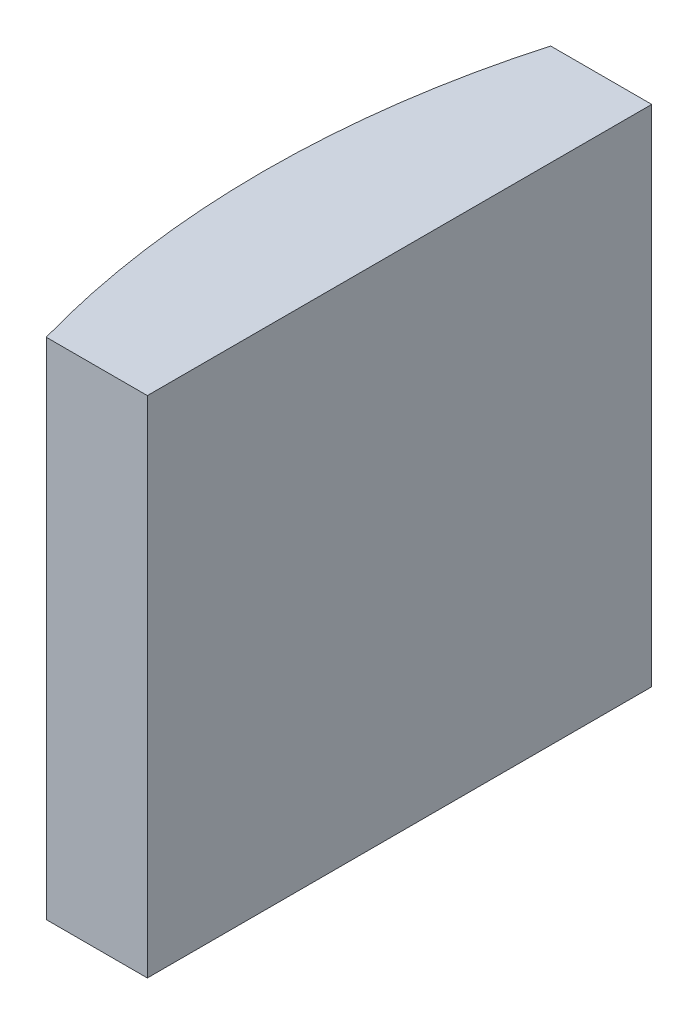
from build123d import *

# Parameters (mm, degrees)
EXTRUDE_1_DEPTH = 10


with BuildPart() as part:
    # 草图1 → 凸台-拉伸1 (new body)
    with BuildSketch(Plane(origin=(0, 0, 0), x_dir=(1, 0, 0), z_dir=(0, 1, 0))):
        with BuildLine():
            Line((-13.269278636, 5), (-11.264795665, 5))
            Line((-11.264795665, 5), (-11.264795665, -5))
            Line((-11.264795665, -5), (-13.269278636, -5))
            ThreePointArc((-13.269278636, -5), (-13.964795665, 0), (-13.269278636, 5))
        make_face()
    extrude(amount=EXTRUDE_1_DEPTH)


solid = part.part
